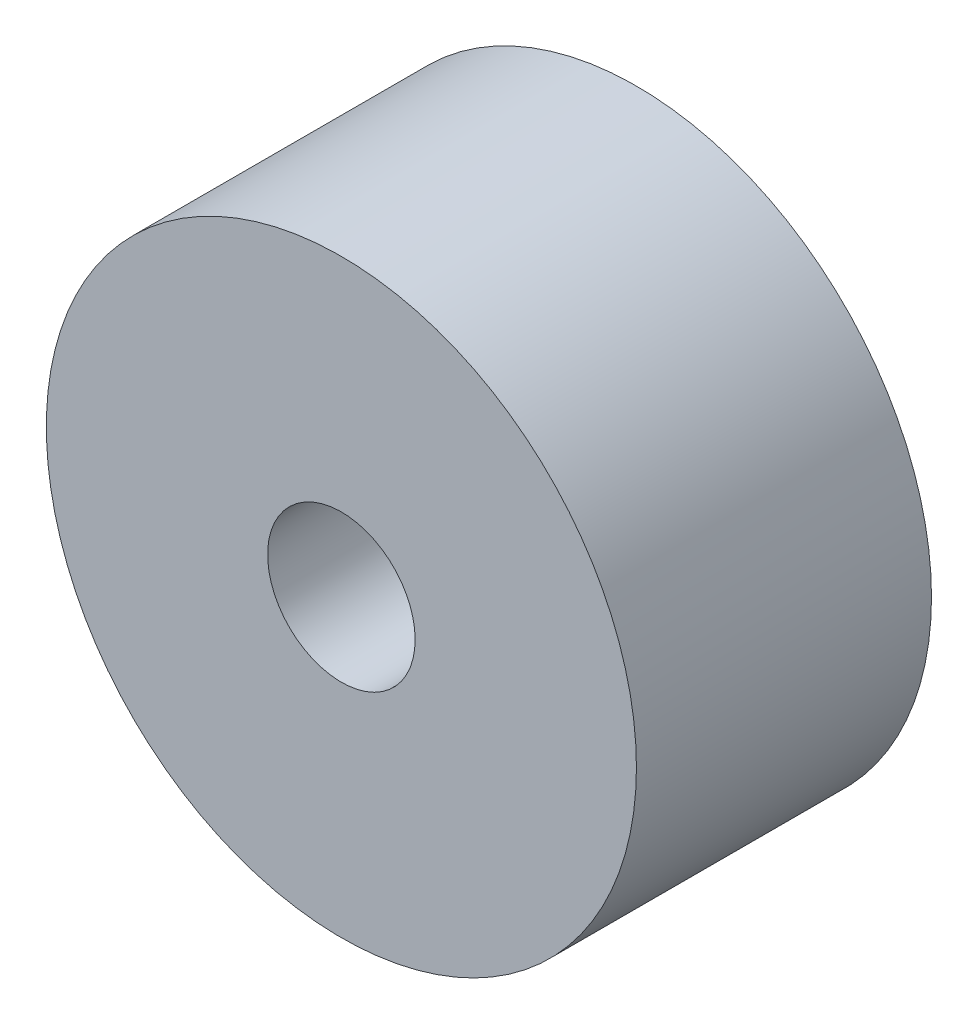
from build123d import *

# Parameters (mm, degrees)
SKETCH1_R           = 6
SKETCH1_R_2         = 1.5
BOSS_EXTRUDE1_DEPTH = 6


with BuildPart() as part:
    # Sketch1 → Boss-Extrude1 (new body)
    with BuildSketch(Plane.XY):
        Circle(SKETCH1_R)
        Circle(SKETCH1_R_2, mode=Mode.SUBTRACT)
    extrude(amount=BOSS_EXTRUDE1_DEPTH)


solid = part.part
